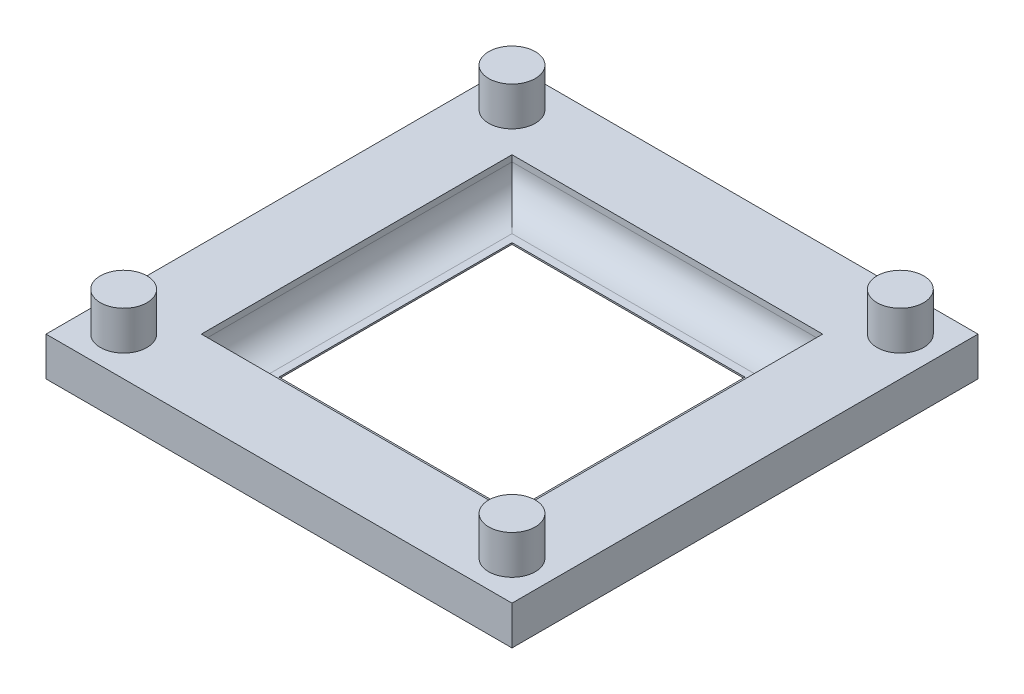
from build123d import *

# Parameters (mm, degrees)
SKETCH1_W           = 20
SKETCH1_H           = 20
SKETCH1_W_2         = 15
SKETCH1_H_2         = 15
BOSS_EXTRUDE3_DEPTH = 0.1
SKETCH1_5_W         = 30
SKETCH1_5_H         = 30
SKETCH1_5_W_2       = 20
SKETCH1_5_H_2       = 20
BOSS_EXTRUDE4_DEPTH = 2.5
FILLET2_R           = 2
SKETCH2_R           = 1.5
BOSS_EXTRUDE5_DEPTH = 2.5


with BuildPart() as part:
    # Sketch1 → Boss-Extrude3 (new body)
    with BuildSketch(Plane(origin=(0, 0, 0), x_dir=(1, 0, 0), z_dir=(0, 1, 0))):
        Rectangle(SKETCH1_W, SKETCH1_H)
        Rectangle(SKETCH1_W_2, SKETCH1_H_2, mode=Mode.SUBTRACT)
    extrude(amount=BOSS_EXTRUDE3_DEPTH)

    # Sketch1_5 → Boss-Extrude4 (add)
    with BuildSketch(Plane(origin=(0, 0, 0), x_dir=(1, 0, 0), z_dir=(0, 1, 0))):
        Rectangle(SKETCH1_5_W, SKETCH1_5_H)
        Rectangle(SKETCH1_5_W_2, SKETCH1_5_H_2, mode=Mode.SUBTRACT)
    extrude(amount=BOSS_EXTRUDE4_DEPTH)

    # Fillet2
    fillet2_edges = [part.edges().sort_by_distance(p)[0] for p in [
        (0, 0.1, 10),
        (0, 0.1, -10),
        (10, 0.1, 0),
        (-10, 0.1, 0),
    ]]
    fillet(fillet2_edges, radius=FILLET2_R)

    # Sketch2 → Boss-Extrude5 (add)
    with BuildSketch(Plane(origin=(0, 2.5, 0), x_dir=(1, 0, 0), z_dir=(0, 1, 0))):
        with Locations((-12.5, 12.5)):
            Circle(SKETCH2_R)
        with Locations((12.5, 12.5)):
            Circle(SKETCH2_R)
        with Locations((12.5, -12.5)):
            Circle(SKETCH2_R)
        with Locations((-12.5, -12.5)):
            Circle(SKETCH2_R)
    extrude(amount=BOSS_EXTRUDE5_DEPTH)


solid = part.part
